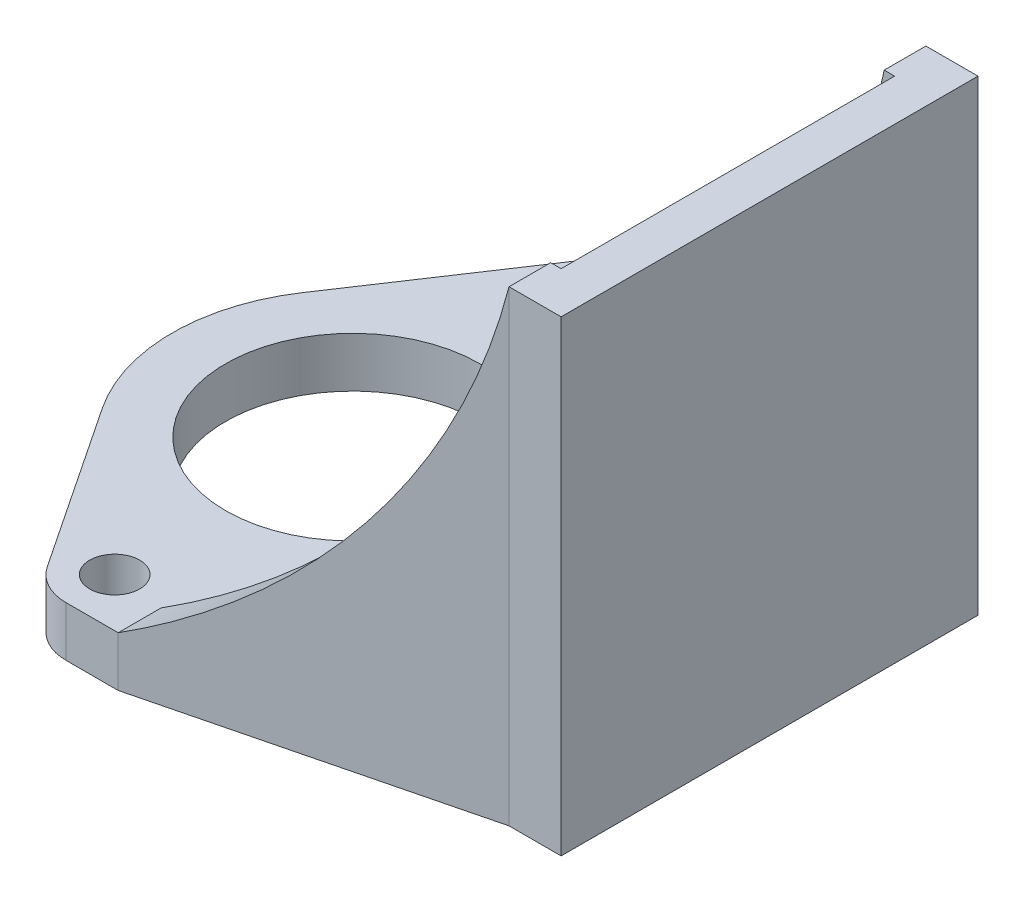
from build123d import *

# Parameters (mm, degrees)
SKETCH1_R           = 7.75
SKETCH1_R_2         = 1.524
BOSS_EXTRUDE1_DEPTH = 3.048
BOSS_EXTRUDE2_DEPTH = 25.4
CUT_EXTRUDE1_DEPTH  = 35.925


with BuildPart() as part:
    # Sketch1 → Boss-Extrude1 (new body)
    with BuildSketch(Plane(origin=(0, 0, 0), x_dir=(1, 0, 0), z_dir=(0, 1, 0))):
        with BuildLine():
            Line((25.4, 12.7), (25.4, -12.7))
            Line((25.4, -12.7), (22.225, -12.7))
            Line((22.225, -12.7), (3.175, -17.4625))
            Line((3.175, -17.4625), (0, -17.4625))
            ThreePointArc((0, -17.4625), (-1.398490879, -17.111633495), (-2.465718563, -16.142144397))
            Line((-2.465718563, -16.142144397), (-9.155410697, -6.097413793))
            ThreePointArc((-9.155410697, -6.097413793), (-11, 0), (-9.155410697, 6.097413793))
            Line((-9.155410697, 6.097413793), (-2.465718563, 16.142144397))
            ThreePointArc((-2.465718563, 16.142144397), (-1.398490879, 17.111633495), (0, 17.4625))
            Line((0, 17.4625), (3.175, 17.4625))
            Line((3.175, 17.4625), (22.225, 12.7))
            Line((22.225, 12.7), (25.4, 12.7))
        make_face()
        Circle(SKETCH1_R, mode=Mode.SUBTRACT)
        with Locations((0, 14.5)):
            Circle(SKETCH1_R_2, mode=Mode.SUBTRACT)
        with Locations((0, -14.5)):
            Circle(SKETCH1_R_2, mode=Mode.SUBTRACT)
    extrude(amount=BOSS_EXTRUDE1_DEPTH)

    # Sketch2 → Boss-Extrude2 (add)
    with BuildSketch(Plane(origin=(0, 3.048, 0), x_dir=(1, 0, 0), z_dir=(0, 1, 0))):
        Polygon((3.175, 17.4625), (3.175, 14.844327928), (21.912311711, 10.16), (22.86, 10.16), (22.86, -10.16), (21.912311711, -10.16), (3.175, -14.844327928), (3.175, -17.4625), (22.225, -12.7), (25.4, -12.7), (25.4, 12.7), (22.225, 12.7), align=None)
    extrude(amount=BOSS_EXTRUDE2_DEPTH)

    # Sketch3 → Cut-Extrude1 (cut, through all)
    with BuildSketch(Plane(origin=(0, 0, -17.4625), x_dir=(-1, 0, 0), z_dir=(0, 0, -1))):
        with BuildLine():
            Line((-22.225, 28.448), (-3.175, 28.448))
            Line((-3.175, 28.448), (-3.175, 3.048))
            ThreePointArc((-3.175, 3.048), (-15.471871229, 13.669096578), (-22.225, 28.448))
        make_face()
    extrude(amount=-CUT_EXTRUDE1_DEPTH, mode=Mode.SUBTRACT)


solid = part.part
